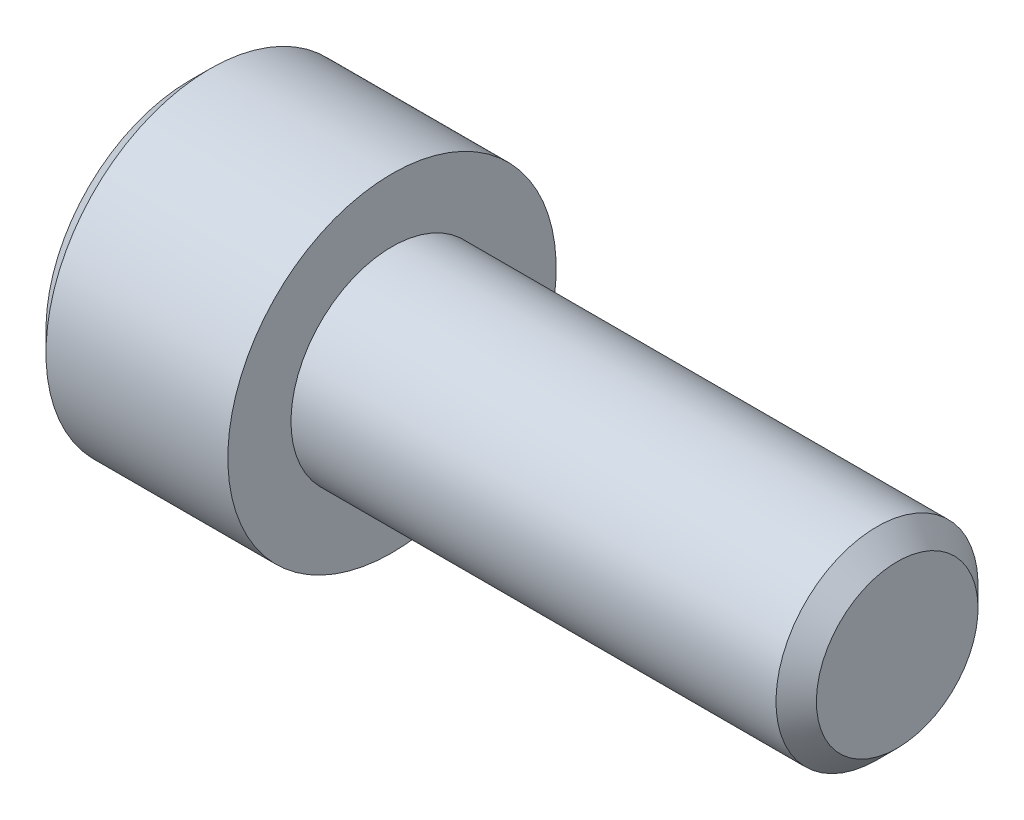
from build123d import *

# Parameters (mm, degrees)
CHAMFER1_SIZE      = 0.8
CUT_EXTRUDE1_DEPTH = 4


with BuildPart() as part:
    # Sketch1 → Revolve1 (revolve)
    with BuildSketch(Plane.XY):
        Polygon((-8, 0), (-8, 6.5), (0, 6.5), (0, 4), (20, 4), (20, 0), align=None)
    revolve(axis=Axis((20, 0, 0), (-1, 0, 0)))

    # Chamfer1
    chamfer1_edges = [part.edges().sort_by_distance(p)[0] for p in [
        (20, -4, 0),
        (-8, -6.5, 0),
    ]]
    chamfer(chamfer1_edges, length=CHAMFER1_SIZE)

    # Sketch2 → Cut-Revolve1 (revolve, cut)
    with BuildSketch(Plane.XY):
        Polygon((-8, 0), (-8, 3), (-4, 3), (-3.196152423, 0), align=None)
    revolve(axis=Axis((-3.196152423, 0, 0), (-1, 0, 0)), mode=Mode.SUBTRACT)

    # Sketch3 → Cut-Extrude1 (cut)
    with BuildSketch(Plane(origin=(-8, 0, 0), x_dir=(0, 0, -1), z_dir=(1, 0, 0))):
        Polygon((-3, 1.732050808), (-3, -1.732050808), (0, -3.464101615), (3, -1.732050808), (3, 1.732050808), (0, 3.464101615), align=None)
    extrude(amount=CUT_EXTRUDE1_DEPTH, mode=Mode.SUBTRACT)


solid = part.part
